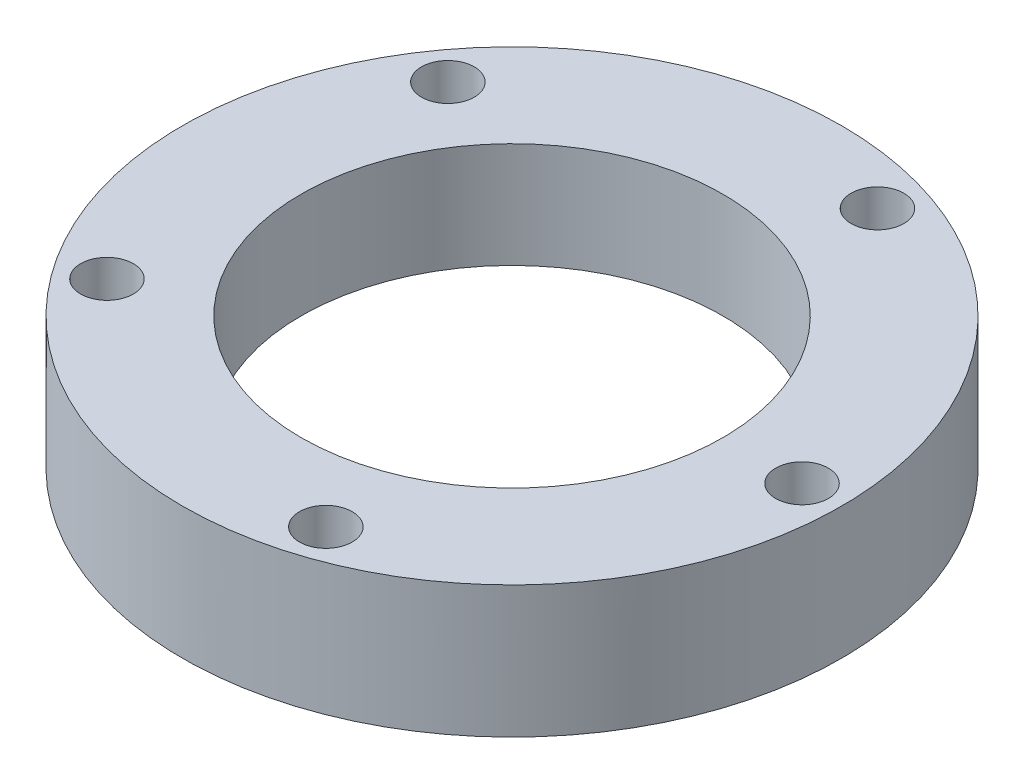
from build123d import *

# Parameters (mm, degrees)
SKETCH_1_R          = 12.5
EXTRUDE_1_DEPTH     = 4
SKETCH_2_R          = 1
EXTRUDE_2_DEPTH     = 7.5
SKETCH_5_R          = 6
CUT_EXTRUDE_1_DEPTH = 10
SKETCH_7_R          = 1
CUT_EXTRUDE_2_DEPTH = 7.5
SKETCH_8_R          = 12.5
SKETCH_8_R_2        = 6
CUT_EXTRUDE_3_DEPTH = 10
SKETCH_9_R          = 1
EXTRUDE_3_DEPTH     = 10
SKETCH_10_R         = 1
CUT_EXTRUDE_4_DEPTH = 14
SKETCH_11_R         = 8
CUT_EXTRUDE_5_DEPTH = 10
SKETCH_13_R         = 12.5
SKETCH_13_R_2       = 9.6
EXTRUDE_5_DEPTH     = 1


with BuildPart() as part:
    # 草图1 → 凸台-拉伸1 (new body)
    with BuildSketch(Plane(origin=(0, 0, 0), x_dir=(1, 0, 0), z_dir=(0, 1, 0))):
        Circle(SKETCH_1_R)
    extrude(amount=EXTRUDE_1_DEPTH)

    # 草图2 → 凸台-拉伸2 (add)
    with BuildSketch(Plane(origin=(0, 4, 0), x_dir=(1, 0, 0), z_dir=(0, 1, 0))):
        with Locations((10, 0)):
            Circle(SKETCH_2_R)
        with Locations((3.399186938, -10.461621679)):
            Circle(SKETCH_2_R)
        with Locations((-8.590169944, -7.416694292)):
            Circle(SKETCH_2_R)
        with Locations((-9.399186938, 4.926796007)):
            Circle(SKETCH_2_R)
        with Locations((2.090169944, 9.510565163)):
            Circle(SKETCH_2_R)
    extrude(amount=EXTRUDE_2_DEPTH)

    # 草图5 → 切除-拉伸1 (cut)
    with BuildSketch(Plane(origin=(0, 4, 0), x_dir=(1, 0, 0), z_dir=(0, 1, 0))):
        Circle(SKETCH_5_R)
    extrude(amount=-CUT_EXTRUDE_1_DEPTH, mode=Mode.SUBTRACT)

    # 草图7 → 切除-拉伸2 (cut)
    with BuildSketch(Plane(origin=(0, 11.5, 0), x_dir=(1, 0, 0), z_dir=(0, 1, 0))):
        with Locations((-9.399186938, 4.926796007)):
            Circle(SKETCH_7_R)
    extrude(amount=-CUT_EXTRUDE_2_DEPTH, mode=Mode.SUBTRACT)

    # 草图8 → 切除-拉伸3 (cut)
    with BuildSketch(Plane(origin=(0, 4, 0), x_dir=(1, 0, 0), z_dir=(0, 1, 0))):
        Circle(SKETCH_8_R)
        Circle(SKETCH_8_R_2, mode=Mode.SUBTRACT)
    extrude(amount=CUT_EXTRUDE_3_DEPTH, mode=Mode.SUBTRACT)

    # 草图9 → 凸台-拉伸3 (add)
    with BuildSketch(Plane(origin=(0, 4, 0), x_dir=(1, 0, 0), z_dir=(0, 1, 0))):
        with Locations((11, 0)):
            Circle(SKETCH_9_R)
        with Locations((3.399186938, -10.461621679)):
            Circle(SKETCH_9_R)
        with Locations((-8.899186938, -6.465637775)):
            Circle(SKETCH_9_R)
        with Locations((-8.899186938, 6.465637775)):
            Circle(SKETCH_9_R)
        with Locations((3.399186938, 10.461621679)):
            Circle(SKETCH_9_R)
    extrude(amount=EXTRUDE_3_DEPTH)

    # 草图10 → 切除-拉伸4 (cut)
    with BuildSketch(Plane(origin=(0, 14, 0), x_dir=(1, 0, 0), z_dir=(0, 1, 0))):
        with Locations((-8.899186938, -6.465637775)):
            Circle(SKETCH_10_R)
        with Locations((3.399186938, -10.461621679)):
            Circle(SKETCH_10_R)
        with Locations((11, 0)):
            Circle(SKETCH_10_R)
        with Locations((3.399186938, 10.461621679)):
            Circle(SKETCH_10_R)
        with Locations((-8.899186938, 6.465637775)):
            Circle(SKETCH_10_R)
    extrude(amount=-CUT_EXTRUDE_4_DEPTH, mode=Mode.SUBTRACT)

    # 草图11 → 切除-拉伸5 (cut)
    with BuildSketch(Plane(origin=(0, 4, 0), x_dir=(1, 0, 0), z_dir=(0, 1, 0))):
        Circle(SKETCH_11_R)
    extrude(amount=-CUT_EXTRUDE_5_DEPTH, mode=Mode.SUBTRACT)

    # 草图13 → 凸台-拉伸5 (add)
    with BuildSketch(Plane.XZ):
        Circle(SKETCH_13_R)
        Circle(SKETCH_13_R_2, mode=Mode.SUBTRACT)
    extrude(amount=EXTRUDE_5_DEPTH)


solid = part.part
